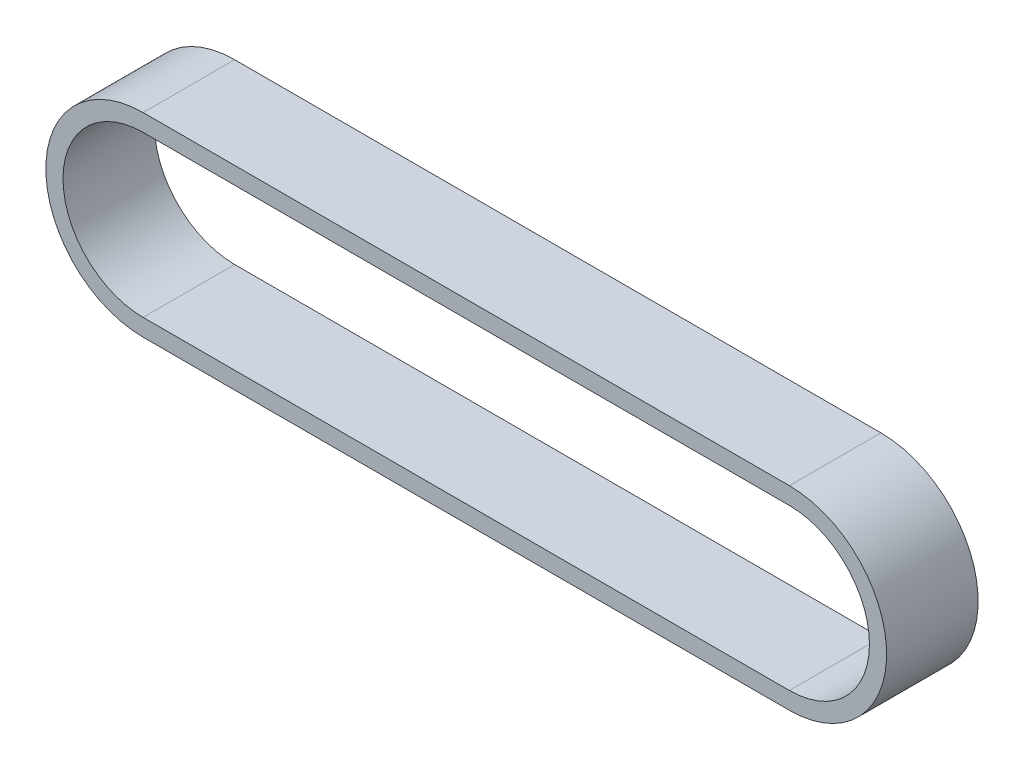
from build123d import *

# Parameters (mm, degrees)
ESTRUSIONE_ESTRUSIONE2_DEPTH = 6.4


with BuildPart() as part:
    # Schizzo1 (on Front Plane) → Estrusione-Estrusione2 (new body)
    with BuildSketch(Plane.XY):
        with BuildLine():
            Line((0, -6.8), (-45.177427992, -6.8))
            ThreePointArc((-45.177427992, -6.8), (-51.977427992, 0), (-45.177427992, 6.8))
            Line((-45.177427992, 6.8), (0, 6.8))
            ThreePointArc((0, 6.8), (6.8, 0), (0, -6.8))
        make_face()
        with BuildLine():
            Line((0, -5.6), (-45.177427992, -5.6))
            ThreePointArc((-45.177427992, -5.6), (-50.777427992, 0), (-45.177427992, 5.6))
            Line((-45.177427992, 5.6), (0, 5.6))
            ThreePointArc((0, 5.6), (5.6, 0), (0, -5.6))
        make_face(mode=Mode.SUBTRACT)
    extrude(amount=ESTRUSIONE_ESTRUSIONE2_DEPTH)


solid = part.part
